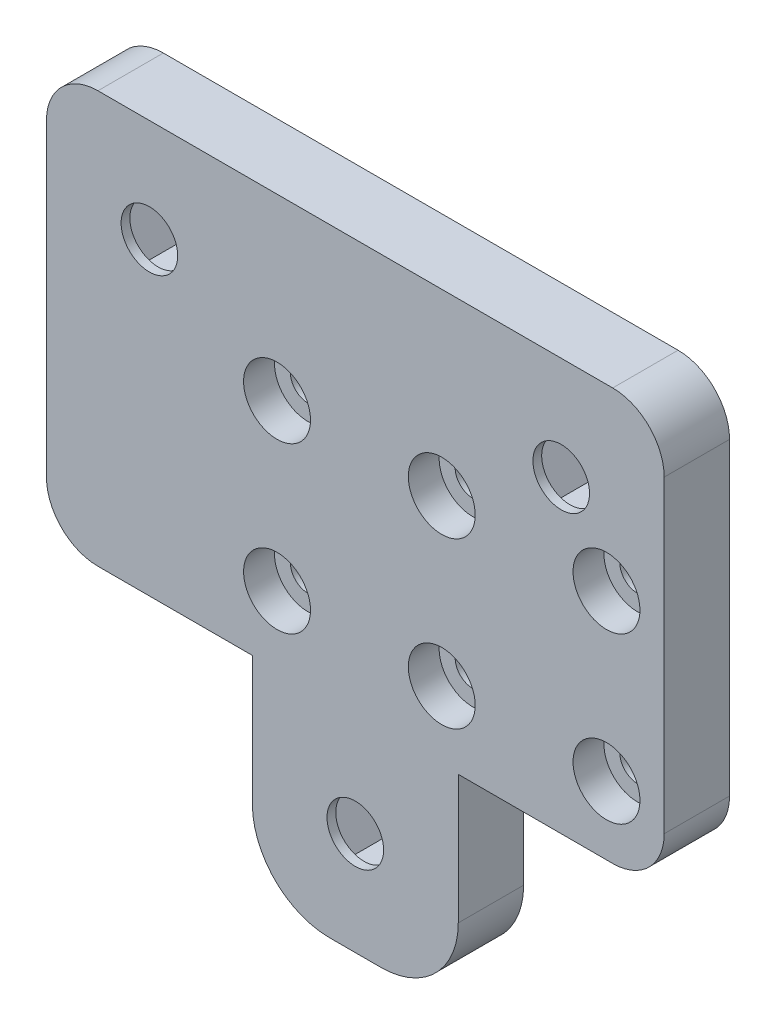
from build123d import *

# Parameters (mm, degrees)
BOSS_EXTRUDE1_DEPTH            = 6.35
M5_CLEARANCE_HOLE1_D           = 5.5
CBORE_FOR_M3_SHCS1_D           = 3.4
CBORE_FOR_M3_SHCS1_CBORE_D     = 6.5
CBORE_FOR_M3_SHCS1_CBORE_DEPTH = 3
CUT_EXTRUDE1_DEPTH             = 5.5


with BuildPart() as part:
    # Sketch1 → Boss-Extrude1 (new body)
    with BuildSketch(Plane.XY):
        with BuildLine():
            Line((5, 0), (20, 0))
            Line((20, 0), (20, -12.5))
            ThreePointArc((20, -12.5), (22.196699141, -17.803300859), (27.5, -20))
            Line((27.5, -20), (32.5, -20))
            ThreePointArc((32.5, -20), (37.803300859, -17.803300859), (40, -12.5))
            Line((40, -12.5), (40, 0))
            Line((40, 0), (55, 0))
            ThreePointArc((55, 0), (58.535533906, 1.464466094), (60, 5))
            Line((60, 5), (60, 35))
            ThreePointArc((60, 35), (58.535533906, 38.535533906), (55, 40))
            Line((55, 40), (5, 40))
            ThreePointArc((5, 40), (1.464466094, 38.535533906), (0, 35))
            Line((0, 35), (0, 5))
            ThreePointArc((0, 5), (1.464466094, 1.464466094), (5, 0))
        make_face()
    extrude(amount=BOSS_EXTRUDE1_DEPTH)

    # M5 Clearance Hole1 (through all)
    with Locations(Plane.XY.offset(6.35)):
        with Locations((30, -10), (10, 30), (50, 30)):
            Hole(M5_CLEARANCE_HOLE1_D / 2)

    # CBORE for M3 SHCS1 (through all)
    with Locations(Plane.XY.offset(6.35)):
        with Locations((38.396727498, 22.625800799), (54.396727498, 6.625800799), (38.396727498, 6.625800799), (54.396727498, 22.625800799), (22.396727498, 6.625800799), (22.396727498, 22.625800799)):
            CounterBoreHole(CBORE_FOR_M3_SHCS1_D / 2, CBORE_FOR_M3_SHCS1_CBORE_D / 2, CBORE_FOR_M3_SHCS1_CBORE_DEPTH)

    # Sketch7 → Cut-Extrude1 (cut)
    with BuildSketch(Plane(origin=(0, 0, 0), x_dir=(-1, 0, 0), z_dir=(0, 0, -1))):
        Polygon((-45.265727793, 30), (-47.632863896, 34.1), (-52.367136104, 34.1), (-54.734272207, 30), (-52.367136104, 25.9), (-47.632863896, 25.9), align=None)
        Polygon((-5.265727793, 30), (-7.632863896, 34.1), (-12.367136104, 34.1), (-14.734272207, 30), (-12.367136104, 25.9), (-7.632863896, 25.9), align=None)
        Polygon((-25.265727793, -10), (-27.632863896, -5.9), (-32.367136104, -5.9), (-34.734272207, -10), (-32.367136104, -14.1), (-27.632863896, -14.1), align=None)
    extrude(amount=-CUT_EXTRUDE1_DEPTH, mode=Mode.SUBTRACT)


solid = part.part
